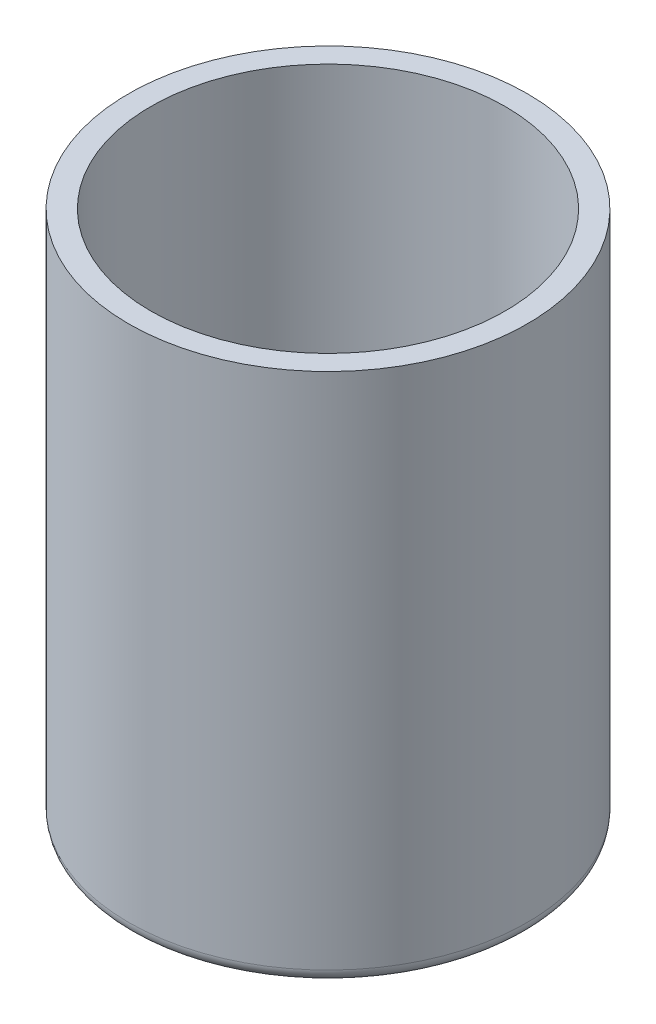
from build123d import *

# Parameters (mm, degrees)
SKETCH1_R           = 45
BOSS_EXTRUDE1_DEPTH = 120
SKETCH3_R           = 40
CUT_EXTRUDE1_DEPTH  = 115
SKETCH2_R           = 6.2
CUT_EXTRUDE2_DEPTH  = 5
SKETCH4_R           = 3
CUT_EXTRUDE3_DEPTH  = 5
FILLET1_R           = 3
FILLET2_R           = 1
FILLET3_R           = 1
FILLET4_R           = 1
FILLET5_R           = 1
SKETCH5_R           = 5
CUT_EXTRUDE4_DEPTH  = 5
FILLET6_R           = 1


with BuildPart() as part:
    # Sketch1 → Boss-Extrude1 (new body)
    with BuildSketch(Plane(origin=(0, 0, 0), x_dir=(1, 0, 0), z_dir=(0, 1, 0))):
        Circle(SKETCH1_R)
    extrude(amount=BOSS_EXTRUDE1_DEPTH)

    # Sketch3 → Cut-Extrude1 (cut)
    with BuildSketch(Plane(origin=(0, 120, 0), x_dir=(1, 0, 0), z_dir=(0, 1, 0))):
        Circle(SKETCH3_R)
    extrude(amount=-CUT_EXTRUDE1_DEPTH, mode=Mode.SUBTRACT)

    # Sketch2 → Cut-Extrude2 (cut)
    with BuildSketch(Plane(origin=(0, 0, 0), x_dir=(1, 0, 0), z_dir=(0, 1, 0))):
        with Locations((30, 0)):
            Circle(SKETCH2_R)
        with Locations((-30, 0)):
            Circle(SKETCH2_R)
    extrude(amount=CUT_EXTRUDE2_DEPTH, mode=Mode.SUBTRACT)

    # Sketch4 → Cut-Extrude3 (cut)
    with BuildSketch(Plane.XZ):
        with Locations((0, 15)):
            Circle(SKETCH4_R)
        with Locations((0, -15)):
            Circle(SKETCH4_R)
    extrude(amount=-CUT_EXTRUDE3_DEPTH, mode=Mode.SUBTRACT)

    # Fillet1
    fillet1_edges = [part.edges().sort_by_distance(p)[0] for p in [
        (-45, 0, 0),
    ]]
    fillet(fillet1_edges, radius=FILLET1_R)

    # Fillet2
    fillet2_edges = [part.edges().sort_by_distance(p)[0] for p in [
        (-36.2, 0, 0),
    ]]
    fillet(fillet2_edges, radius=FILLET2_R)

    # Fillet3
    fillet3_edges = [part.edges().sort_by_distance(p)[0] for p in [
        (23.8, 0, 0),
    ]]
    fillet(fillet3_edges, radius=FILLET3_R)

    # Fillet4
    fillet4_edges = [part.edges().sort_by_distance(p)[0] for p in [
        (-3, 0, -15),
    ]]
    fillet(fillet4_edges, radius=FILLET4_R)

    # Fillet5
    fillet5_edges = [part.edges().sort_by_distance(p)[0] for p in [
        (-3, 0, 15),
    ]]
    fillet(fillet5_edges, radius=FILLET5_R)

    # Sketch5 → Cut-Extrude4 (cut)
    with BuildSketch(Plane.XZ):
        Circle(SKETCH5_R)
    extrude(amount=-CUT_EXTRUDE4_DEPTH, mode=Mode.SUBTRACT)

    # Fillet6
    fillet6_edges = [part.edges().sort_by_distance(p)[0] for p in [
        (-5, 0, 0),
    ]]
    fillet(fillet6_edges, radius=FILLET6_R)


solid = part.part
